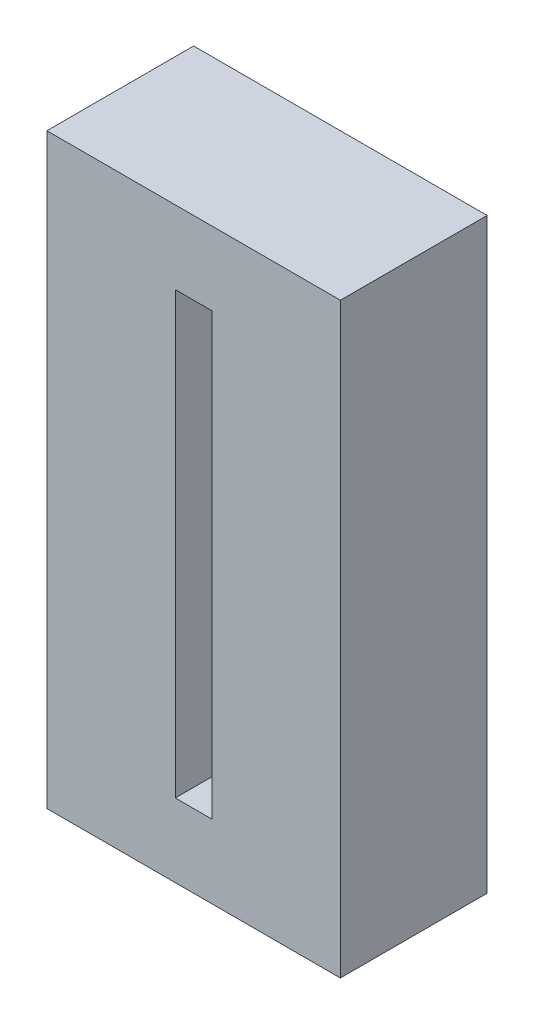
from build123d import *

# Parameters (mm, degrees)
SKETCH1_W           = 101.6
SKETCH1_H           = 203.2
SKETCH1_W_2         = 12.7
SKETCH1_H_2         = 152.4
BOSS_EXTRUDE1_DEPTH = 50.8


with BuildPart() as part:
    # Sketch1 → Boss-Extrude1 (new body)
    with BuildSketch(Plane.XY):
        with Locations((50.8, 101.6)):
            Rectangle(SKETCH1_W, SKETCH1_H)
        with Locations((50.8, 101.6)):
            Rectangle(SKETCH1_W_2, SKETCH1_H_2, mode=Mode.SUBTRACT)
    extrude(amount=BOSS_EXTRUDE1_DEPTH)


solid = part.part
